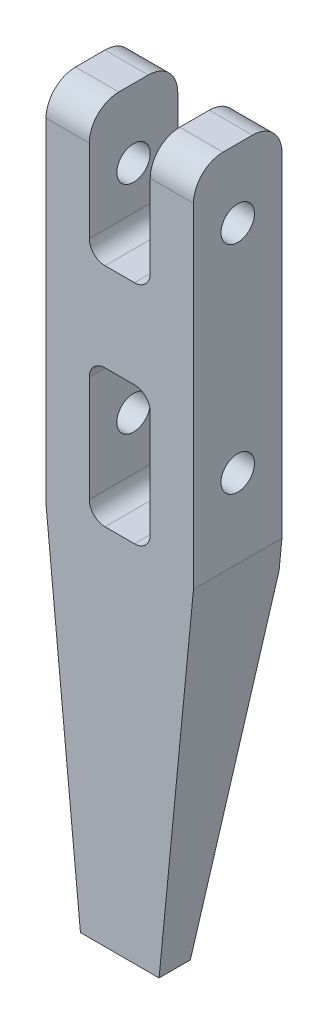
from build123d import *

# Parameters (mm, degrees)
SKETCH_1_R               = 0.85
EXTRUDE_1_DEPTH          = 3.75
SKETCH_2_W               = 3.1
SKETCH_2_H               = 7.782870542
SKETCH_2_H_2             = 7
CUT_EXTRUDE_1_DEPTH      = 3.25
CUT_EXTRUDE_1_DEPTH_BACK = 3.25
FILLET_1_R               = 1.5
FILLET_2_R               = 0.8
CUT_EXTRUDE_2_DEPTH      = 5.5


with BuildPart() as part:
    # 草图1 → 凸台-拉伸1 (new body, symmetric)
    with BuildSketch(Plane(origin=(0, 0, 0), x_dir=(0, 0, -1), z_dir=(1, 0, 0))):
        Polygon((-2.25, 3.5), (2.25, 3.5), (2.25, -16.5), (-0.659395182, -33), (-2.25, -33), align=None)
        Circle(SKETCH_1_R, mode=Mode.SUBTRACT)
        with Locations((0, -11)):
            Circle(SKETCH_1_R, mode=Mode.SUBTRACT)
    extrude(amount=EXTRUDE_1_DEPTH, both=True)

    # 草图2 → 切除-拉伸1 (cut, two sides)
    with BuildSketch(Plane.XY) as cut_extrude_1_sk:
        with Locations((0, 0.891435271)):
            Rectangle(SKETCH_2_W, SKETCH_2_H)
        with Locations((0, -11)):
            Rectangle(SKETCH_2_W, SKETCH_2_H_2)
    extrude(amount=CUT_EXTRUDE_1_DEPTH, mode=Mode.SUBTRACT)
    extrude(cut_extrude_1_sk.sketch, amount=-CUT_EXTRUDE_1_DEPTH_BACK, mode=Mode.SUBTRACT)

    # 圆角1
    fillet_1_edges = [part.edges().sort_by_distance(p)[0] for p in [
        (-2.65, 3.5, 2.25),
        (-2.65, 3.5, -2.25),
        (2.65, 3.5, 2.25),
        (2.65, 3.5, -2.25),
    ]]
    fillet(fillet_1_edges, radius=FILLET_1_R)

    # 圆角2
    fillet_2_edges = [part.edges().sort_by_distance(p)[0] for p in [
        (-1.55, -3, 0),
        (1.55, -3, 0),
        (-1.55, -7.5, 0),
        (1.55, -7.5, 0),
        (1.55, -14.5, 0),
        (-1.55, -14.5, 0),
    ]]
    fillet(fillet_2_edges, radius=FILLET_2_R)

    # 草图3 → 切除-拉伸2 (cut, through all)
    with BuildSketch(Plane.XY.offset(2.25)):
        Polygon((-3.75, -15), (-2, -33), (-6.857355495, -33), align=None)
        Polygon((6.857355495, -33), (3.75, -15), (2, -33), align=None)
    extrude(amount=-CUT_EXTRUDE_2_DEPTH, mode=Mode.SUBTRACT)


solid = part.part
